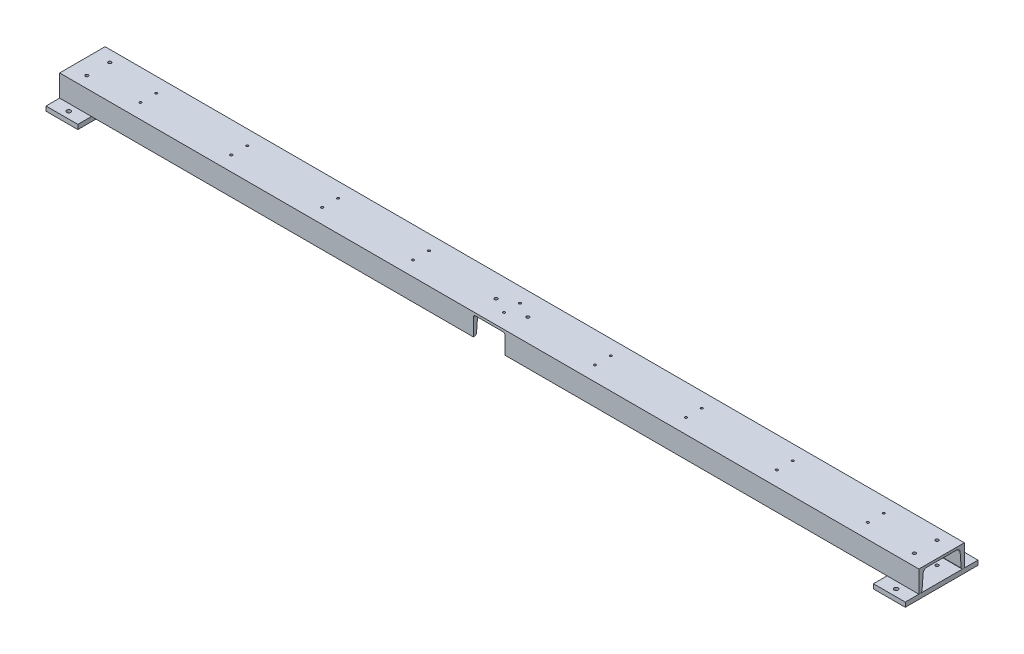
from build123d import *

# Parameters (mm, degrees)
MEMBER_10_1_DEPTH                = 1890
SKETCH_2_W                       = 70
SKETCH_2_H                       = 160
EXTRUDE_1_DEPTH                  = 10
SKETCH_4_W                       = 4.5
SKETCH_4_H                       = 10
HOLE_WIZARD_9_0_9_1_AT_2_COUNT   = 2
HOLE_WIZARD_9_0_9_1_AT_2_PITCH   = 130
HOLE_WIZARD_9_0_9_1_AT_3_COUNT   = 2
HOLE_WIZARD_9_0_9_1_AT_3_PITCH   = 1820
HOLE_WIZARD_9_0_9_1_AT_4_COUNT   = 2
HOLE_WIZARD_9_0_9_1_AT_4_PITCH   = 1824.63695019
SKETCH_6_W                       = 2.5
SKETCH_6_H                       = 48
HOLE_WIZARD_M6_1_AT_2_COUNT      = 2
HOLE_WIZARD_M6_1_AT_2_PITCH      = 35
PATTERN_LINEAR_1_COUNT           = 9
PATTERN_LINEAR_1_PITCH           = 200
PATTERN_LINEAR_1_COPY_1_SKETCH_W = 2.5
PATTERN_LINEAR_1_COPY_1_SKETCH_H = 48
PATTERN_LINEAR_1_COPY_2_SKETCH_W = 2.5
PATTERN_LINEAR_1_COPY_2_SKETCH_H = 48
PATTERN_LINEAR_1_COPY_3_SKETCH_W = 2.5
PATTERN_LINEAR_1_COPY_3_SKETCH_H = 48
PATTERN_LINEAR_1_COPY_4_SKETCH_W = 2.5
PATTERN_LINEAR_1_COPY_4_SKETCH_H = 48
PATTERN_LINEAR_1_COPY_5_SKETCH_W = 2.5
PATTERN_LINEAR_1_COPY_5_SKETCH_H = 48
PATTERN_LINEAR_1_COPY_6_SKETCH_W = 2.5
PATTERN_LINEAR_1_COPY_6_SKETCH_H = 48
PATTERN_LINEAR_1_COPY_7_SKETCH_W = 2.5
PATTERN_LINEAR_1_COPY_7_SKETCH_H = 48
PATTERN_LINEAR_1_COPY_8_SKETCH_W = 2.5
PATTERN_LINEAR_1_COPY_8_SKETCH_H = 48
CUT_EXTRUDE_START                = -10.785948
SKETCH_7_R                       = 15
CUT_EXTRUDE_1_DEPTH              = 10.785948
CUT_EXTRUDE_START_2              = -15.967902
CUT_EXTRUDE_2_DEPTH              = 15.967902
SKETCH_10_R                      = 14
CUT_EXTRUDE_4_DEPTH              = 957.125399037
SKETCH_14_R                      = 14
EXTRUDE_3_DEPTH                  = 45
SKETCH_19_W                      = 3.4
SKETCH_19_H                      = 58
HOLE_WIZARD_M8_1_AT_2_COUNT      = 2
HOLE_WIZARD_M8_1_AT_2_PITCH      = 50
HOLE_WIZARD_M8_1_AT_3_COUNT      = 2
HOLE_WIZARD_M8_1_AT_3_PITCH      = 1820
HOLE_WIZARD_M8_1_AT_4_COUNT      = 2
HOLE_WIZARD_M8_1_AT_4_PITCH      = 1820.686683644
SKETCH_22_W                      = 3.4
SKETCH_22_H                      = 5.3
HOLE_WIZARD_M8_2_AT_2_COUNT      = 2
HOLE_WIZARD_M8_2_AT_2_PITCH      = 70


with BuildPart() as part:
    # Sketch1 → Member 10_1 (new body)
    with BuildSketch(Plane.YZ.offset(-945)):
        with BuildLine():
            Line((0, 0), (0, -100))
            Line((0, -100), (-48, -100))
            Line((-48, -100), (-48, -97.265512699))
            ThreePointArc((-48, -97.265512699), (-46.867155397, -94.376595562), (-44.072544834, -93.027769806))
            Line((-44.072544834, -93.027769806), (-13.154910332, -90.674554065))
            ThreePointArc((-13.154910332, -90.674554065), (-7.565689205, -87.976902554), (-5.3, -82.199068278))
            Line((-5.3, -82.199068278), (-5.3, -17.800931722))
            ThreePointArc((-5.3, -17.800931722), (-7.565689205, -12.023097446), (-13.154910332, -9.325445935))
            Line((-13.154910332, -9.325445935), (-44.072544834, -6.972230194))
            ThreePointArc((-44.072544834, -6.972230194), (-46.867155397, -5.623404438), (-48, -2.734487301))
            Line((-48, -2.734487301), (-48, 0))
            Line((-48, 0), (0, 0))
        make_face()
    extrude(amount=MEMBER_10_1_DEPTH)

    # 草图6 → M6 螺纹孔1 (revolve, cut)
    with BuildSketch(Plane(origin=(-800, 0, -32.5), x_dir=(0, 0, 1), z_dir=(1, 0, 0))):
        with Locations((1.25, 24)):
            Rectangle(SKETCH_6_W, SKETCH_6_H)
    hole_wizard_m6_1 = revolve(axis=Axis((-800, 6.35, -32.5), (0, -1, 0)), mode=Mode.SUBTRACT)

    # M6 螺纹孔1 at 2: M6 螺纹孔1 ×2
    with Locations(*[(0, 0, -i * HOLE_WIZARD_M6_1_AT_2_PITCH) for i in range(1, HOLE_WIZARD_M6_1_AT_2_COUNT)]):
        add(hole_wizard_m6_1, mode=Mode.SUBTRACT)

    # 阵列(线性)1: M6 螺纹孔1 ×9
    with Locations(*[(i * PATTERN_LINEAR_1_PITCH, 0, 0) for i in range(1, PATTERN_LINEAR_1_COUNT)]):
        add(hole_wizard_m6_1, mode=Mode.SUBTRACT)

    # 阵列(线性)1 copy 1 sketch → 阵列(线性)1 copy 1 (revolve, cut)
    with BuildSketch(Plane(origin=(-600, 0, -67.5), x_dir=(0, 0, 1), z_dir=(1, 0, 0))):
        with Locations((1.25, 24)):
            Rectangle(PATTERN_LINEAR_1_COPY_1_SKETCH_W, PATTERN_LINEAR_1_COPY_1_SKETCH_H)
    revolve(axis=Axis((-600, 6.35, -67.5), (0, -1, 0)), mode=Mode.SUBTRACT)

    # 阵列(线性)1 copy 2 sketch → 阵列(线性)1 copy 2 (revolve, cut)
    with BuildSketch(Plane(origin=(-400, 0, -67.5), x_dir=(0, 0, 1), z_dir=(1, 0, 0))):
        with Locations((1.25, 24)):
            Rectangle(PATTERN_LINEAR_1_COPY_2_SKETCH_W, PATTERN_LINEAR_1_COPY_2_SKETCH_H)
    revolve(axis=Axis((-400, 6.35, -67.5), (0, -1, 0)), mode=Mode.SUBTRACT)

    # 阵列(线性)1 copy 3 sketch → 阵列(线性)1 copy 3 (revolve, cut)
    with BuildSketch(Plane(origin=(-200, 0, -67.5), x_dir=(0, 0, 1), z_dir=(1, 0, 0))):
        with Locations((1.25, 24)):
            Rectangle(PATTERN_LINEAR_1_COPY_3_SKETCH_W, PATTERN_LINEAR_1_COPY_3_SKETCH_H)
    revolve(axis=Axis((-200, 6.35, -67.5), (0, -1, 0)), mode=Mode.SUBTRACT)

    # 阵列(线性)1 copy 4 sketch → 阵列(线性)1 copy 4 (revolve, cut)
    with BuildSketch(Plane(origin=(0, 0, -67.5), x_dir=(0, 0, 1), z_dir=(1, 0, 0))):
        with Locations((1.25, 24)):
            Rectangle(PATTERN_LINEAR_1_COPY_4_SKETCH_W, PATTERN_LINEAR_1_COPY_4_SKETCH_H)
    revolve(axis=Axis((0, 6.35, -67.5), (0, -1, 0)), mode=Mode.SUBTRACT)

    # 阵列(线性)1 copy 5 sketch → 阵列(线性)1 copy 5 (revolve, cut)
    with BuildSketch(Plane(origin=(200, 0, -67.5), x_dir=(0, 0, 1), z_dir=(1, 0, 0))):
        with Locations((1.25, 24)):
            Rectangle(PATTERN_LINEAR_1_COPY_5_SKETCH_W, PATTERN_LINEAR_1_COPY_5_SKETCH_H)
    revolve(axis=Axis((200, 6.35, -67.5), (0, -1, 0)), mode=Mode.SUBTRACT)

    # 阵列(线性)1 copy 6 sketch → 阵列(线性)1 copy 6 (revolve, cut)
    with BuildSketch(Plane(origin=(400, 0, -67.5), x_dir=(0, 0, 1), z_dir=(1, 0, 0))):
        with Locations((1.25, 24)):
            Rectangle(PATTERN_LINEAR_1_COPY_6_SKETCH_W, PATTERN_LINEAR_1_COPY_6_SKETCH_H)
    revolve(axis=Axis((400, 6.35, -67.5), (0, -1, 0)), mode=Mode.SUBTRACT)

    # 阵列(线性)1 copy 7 sketch → 阵列(线性)1 copy 7 (revolve, cut)
    with BuildSketch(Plane(origin=(600, 0, -67.5), x_dir=(0, 0, 1), z_dir=(1, 0, 0))):
        with Locations((1.25, 24)):
            Rectangle(PATTERN_LINEAR_1_COPY_7_SKETCH_W, PATTERN_LINEAR_1_COPY_7_SKETCH_H)
    revolve(axis=Axis((600, 6.35, -67.5), (0, -1, 0)), mode=Mode.SUBTRACT)

    # 阵列(线性)1 copy 8 sketch → 阵列(线性)1 copy 8 (revolve, cut)
    with BuildSketch(Plane(origin=(800, 0, -67.5), x_dir=(0, 0, 1), z_dir=(1, 0, 0))):
        with Locations((1.25, 24)):
            Rectangle(PATTERN_LINEAR_1_COPY_8_SKETCH_W, PATTERN_LINEAR_1_COPY_8_SKETCH_H)
    revolve(axis=Axis((800, 6.35, -67.5), (0, -1, 0)), mode=Mode.SUBTRACT)

    # 草图7 → 切除-拉伸1 (cut)
    with BuildSketch(Plane.XY.offset(CUT_EXTRUDE_START)):
        with Locations((0, -24)):
            Circle(SKETCH_7_R)
    extrude(amount=CUT_EXTRUDE_1_DEPTH, mode=Mode.SUBTRACT)

    # 草图13 → 切除-拉伸2 (cut)
    with BuildSketch(Plane.XY.offset(CUT_EXTRUDE_START_2)):
        with BuildLine():
            Line((-30, -5.5), (30, -5.5))
            ThreePointArc((30, -5.5), (33.535533906, -6.964466094), (35, -10.5))
            Line((35, -10.5), (35, -48))
            Line((35, -48), (-35, -48))
            Line((-35, -48), (-35, -10.5))
            ThreePointArc((-35, -10.5), (-33.535533906, -6.964466094), (-30, -5.5))
        make_face()
    extrude(amount=CUT_EXTRUDE_2_DEPTH, mode=Mode.SUBTRACT)

    # 草图10 → 切除-拉伸4 (cut, through all)
    with BuildSketch(Plane(origin=(0, 7.197994556, -100), x_dir=(1, 0, 0), z_dir=(0, 0, 1))):
        with Locations((0, -42.197994556)):
            Circle(SKETCH_10_R)
    extrude(amount=CUT_EXTRUDE_4_DEPTH, mode=Mode.SUBTRACT)


with BuildPart() as body_2:
    # 草图2 → 凸台-拉伸1 (new body)
    with BuildSketch(Plane.XZ.offset(48)):
        with Locations((-910, -50)):
            Rectangle(SKETCH_2_W, SKETCH_2_H)
    extrude(amount=EXTRUDE_1_DEPTH)


with BuildPart() as body_3:
    # 镜向3: mirrored copy
    add(body_2.part.mirror(Plane(origin=(0, 0, 0), x_dir=(0, 0, 1), z_dir=(1, 0, 0))))

    # 草图4 → Ø9.0 (9) 直径孔1 (revolve, cut)
    with BuildSketch(Plane(origin=(910, -48, -115), x_dir=(0, 0, 1), z_dir=(1, 0, 0))):
        with Locations((2.25, 5)):
            Rectangle(SKETCH_4_W, SKETCH_4_H)
    hole_wizard_9_0_9_1 = revolve(axis=Axis((910, -41.65, -115), (0, -1, 0)), mode=Mode.SUBTRACT)

    # Ø9.0 (9) 直径孔1 at 2: Ø9.0 (9) 直径孔1 ×2
    with Locations(*[(0, 0, i * HOLE_WIZARD_9_0_9_1_AT_2_PITCH) for i in range(1, HOLE_WIZARD_9_0_9_1_AT_2_COUNT)]):
        add(hole_wizard_9_0_9_1, mode=Mode.SUBTRACT)


with BuildPart() as body_2_1:
    add(body_2.part)

    # Ø9.0 (9) 直径孔1 at 3: Ø9.0 (9) 直径孔1 ×2
    with Locations(*[(-i * HOLE_WIZARD_9_0_9_1_AT_3_PITCH, 0, 0) for i in range(1, HOLE_WIZARD_9_0_9_1_AT_3_COUNT)]):
        add(hole_wizard_9_0_9_1, mode=Mode.SUBTRACT)

    # Ø9.0 (9) 直径孔1 at 4: Ø9.0 (9) 直径孔1 ×2
    with Locations(*[Vector(-0.997458699830735, 0, 0.07124704998790966) * (i * HOLE_WIZARD_9_0_9_1_AT_4_PITCH) for i in range(1, HOLE_WIZARD_9_0_9_1_AT_4_COUNT)]):
        add(hole_wizard_9_0_9_1, mode=Mode.SUBTRACT)


with BuildPart() as body_4:
    # 草图14 → 凸台-拉伸3 (new body)
    with BuildSketch(Plane(origin=(0, 0, -100), x_dir=(-1, 0, 0), z_dir=(0, 0, -1))):
        with Locations((0, -35)):
            Circle(SKETCH_14_R)
    extrude(amount=-EXTRUDE_3_DEPTH)

    # 草图17 → M22x1.5 螺纹孔1 (revolve, cut)
    with BuildSketch(Plane(origin=(0, -35, -55), x_dir=(0, -1, 0), z_dir=(1, 0, 0))):
        Polygon((0, 0), (0, 54.658821345), (10.25, 48.5), (10.25, 0), align=None)
    revolve(axis=Axis((0, -35, -48.65), (0, 0, -1)), mode=Mode.SUBTRACT)


with BuildPart() as hole_wizard_m8_1_tool:
    # 草图19 → M8 螺纹孔1 (revolve)
    with BuildSketch(Plane(origin=(-910, 0, -75), x_dir=(0, 0, 1), z_dir=(1, 0, 0))):
        with Locations((1.7, 29)):
            Rectangle(SKETCH_19_W, SKETCH_19_H)
    hole_wizard_m8_1 = revolve(axis=Axis((-910, 6.35, -75), (0, -1, 0)))


with BuildPart() as part_1:
    add(part.part)

    # M8 螺纹孔1: cut by hole_wizard_m8_1_tool
    add(hole_wizard_m8_1_tool.part, mode=Mode.SUBTRACT)


with BuildPart() as body_2_2:
    add(body_2_1.part)

    # M8 螺纹孔1: cut by hole_wizard_m8_1_tool
    add(hole_wizard_m8_1_tool.part, mode=Mode.SUBTRACT)


with BuildPart() as hole_wizard_m8_1_at_2_tool:
    # M8 螺纹孔1 at 2: M8 螺纹孔1 ×2
    with Locations(*[(0, 0, i * HOLE_WIZARD_M8_1_AT_2_PITCH) for i in range(1, HOLE_WIZARD_M8_1_AT_2_COUNT)]):
        add(hole_wizard_m8_1)


with BuildPart() as part_2:
    add(part_1.part)

    # M8 螺纹孔1 at 2: cut by hole_wizard_m8_1_at_2_tool
    add(hole_wizard_m8_1_at_2_tool.part, mode=Mode.SUBTRACT)


with BuildPart() as body_2_3:
    add(body_2_2.part)

    # M8 螺纹孔1 at 2: cut by hole_wizard_m8_1_at_2_tool
    add(hole_wizard_m8_1_at_2_tool.part, mode=Mode.SUBTRACT)


with BuildPart() as hole_wizard_m8_1_at_3_tool:
    # M8 螺纹孔1 at 3: M8 螺纹孔1 ×2
    with Locations(*[(i * HOLE_WIZARD_M8_1_AT_3_PITCH, 0, 0) for i in range(1, HOLE_WIZARD_M8_1_AT_3_COUNT)]):
        add(hole_wizard_m8_1)


with BuildPart() as part_3:
    add(part_2.part)

    # M8 螺纹孔1 at 3: cut by hole_wizard_m8_1_at_3_tool
    add(hole_wizard_m8_1_at_3_tool.part, mode=Mode.SUBTRACT)


with BuildPart() as body_3_1:
    add(body_3.part)

    # M8 螺纹孔1 at 3: cut by hole_wizard_m8_1_at_3_tool
    add(hole_wizard_m8_1_at_3_tool.part, mode=Mode.SUBTRACT)


with BuildPart() as hole_wizard_m8_1_at_4_tool:
    # M8 螺纹孔1 at 4: M8 螺纹孔1 ×2
    with Locations(*[Vector(0.9996228435949158, 0, 0.027462166032827365) * (i * HOLE_WIZARD_M8_1_AT_4_PITCH) for i in range(1, HOLE_WIZARD_M8_1_AT_4_COUNT)]):
        add(hole_wizard_m8_1)


with BuildPart() as part_4:
    add(part_3.part)

    # M8 螺纹孔1 at 4: cut by hole_wizard_m8_1_at_4_tool
    add(hole_wizard_m8_1_at_4_tool.part, mode=Mode.SUBTRACT)

    # 草图22 → M8 螺纹孔2 (revolve, cut)
    with BuildSketch(Plane(origin=(35, -5.3, -50), x_dir=(0, 0, -1), z_dir=(1, 0, 0))):
        with Locations((1.7, 2.65)):
            Rectangle(SKETCH_22_W, SKETCH_22_H)
    hole_wizard_m8_2 = revolve(axis=Axis((35, -11.65, -50), (0, 1, 0)), mode=Mode.SUBTRACT)

    # M8 螺纹孔2 at 2: M8 螺纹孔2 ×2
    with Locations(*[(-i * HOLE_WIZARD_M8_2_AT_2_PITCH, 0, 0) for i in range(1, HOLE_WIZARD_M8_2_AT_2_COUNT)]):
        add(hole_wizard_m8_2, mode=Mode.SUBTRACT)


with BuildPart() as body_3_2:
    add(body_3_1.part)

    # M8 螺纹孔1 at 4: cut by hole_wizard_m8_1_at_4_tool
    add(hole_wizard_m8_1_at_4_tool.part, mode=Mode.SUBTRACT)


solid = Compound([body_4.part, body_2_3.part, part_4.part, body_3_2.part])
